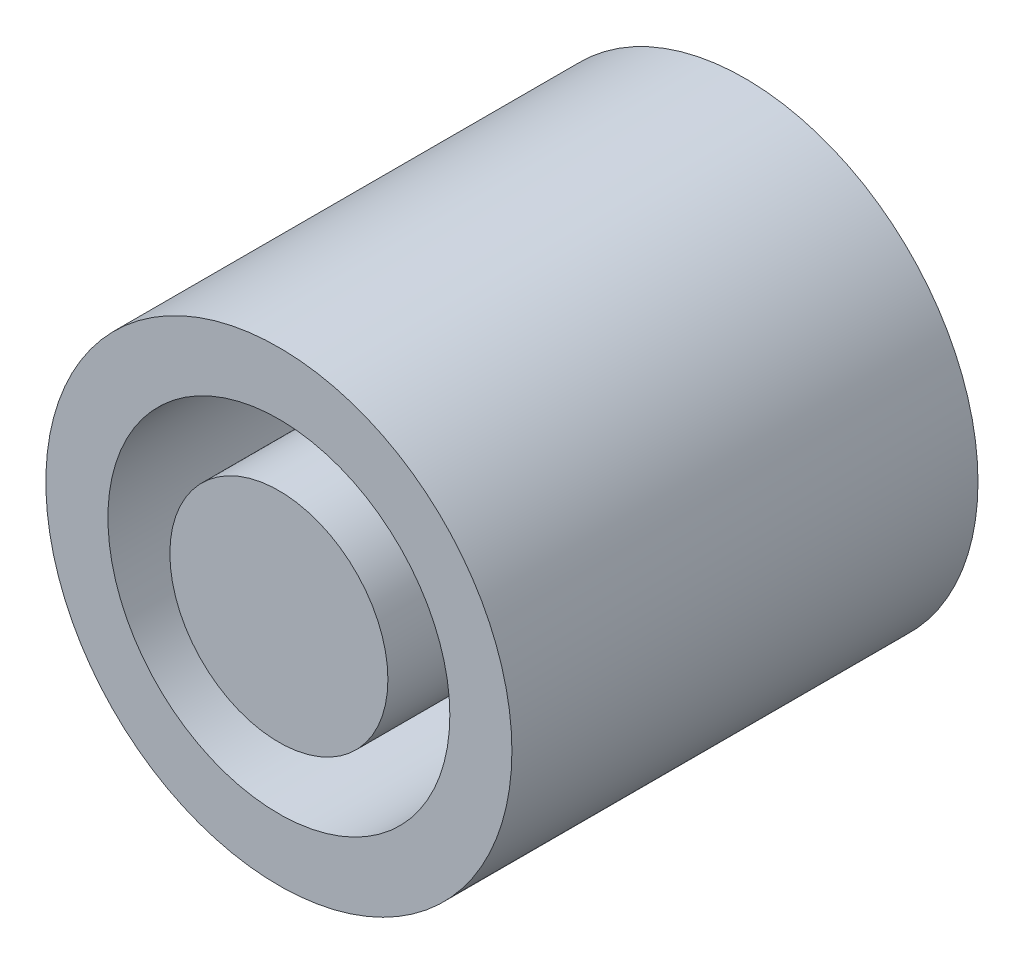
from build123d import *

# Parameters (mm, degrees)
SKETCH1_R      = 0.025
EXTRUDE1_DEPTH = 0.05
SKETCH2_R      = 0.018340358
SKETCH2_R_2    = 0.011695172
EXTRUDE2_DEPTH = 0.04


with BuildPart() as part:
    # Sketch1 → Extrude1 (new body)
    with BuildSketch(Plane.XY):
        Circle(SKETCH1_R)
    extrude(amount=-EXTRUDE1_DEPTH)

    # Sketch2 → Extrude2 (cut)
    with BuildSketch(Plane.XY):
        Circle(SKETCH2_R)
        Circle(SKETCH2_R_2, mode=Mode.SUBTRACT)
    extrude(amount=-EXTRUDE2_DEPTH, mode=Mode.SUBTRACT)


solid = part.part
